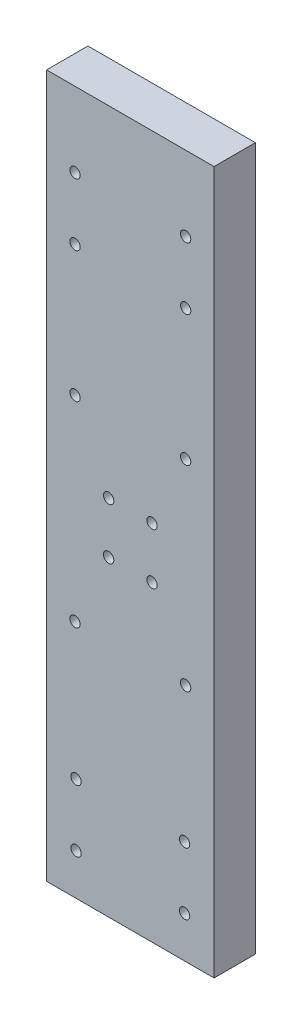
from build123d import *

# Parameters (mm, degrees)
SKETCH1_W           = 16.2
SKETCH1_H           = 67.99
SKETCH1_R           = 0.5
BOSS_EXTRUDE1_DEPTH = 4


with BuildPart() as part:
    # Sketch1 → Boss-Extrude1 (new body)
    with BuildSketch(Plane.XY):
        with Locations((8.1, 33.995)):
            Rectangle(SKETCH1_W, SKETCH1_H)
        with Locations((6, 30.15)):
            Circle(SKETCH1_R, mode=Mode.SUBTRACT)
        with Locations((10.2, 30.15)):
            Circle(SKETCH1_R, mode=Mode.SUBTRACT)
        with Locations((10.2, 35.11)):
            Circle(SKETCH1_R, mode=Mode.SUBTRACT)
        with Locations((13.45, 60.76)):
            Circle(SKETCH1_R, mode=Mode.SUBTRACT)
        with Locations((13.45, 54.76)):
            Circle(SKETCH1_R, mode=Mode.SUBTRACT)
        with Locations((2.75, 60.76)):
            Circle(SKETCH1_R, mode=Mode.SUBTRACT)
        with Locations((6, 35.11)):
            Circle(SKETCH1_R, mode=Mode.SUBTRACT)
        with Locations((2.75, 42.11)):
            Circle(SKETCH1_R, mode=Mode.SUBTRACT)
        with Locations((2.85, 10)):
            Circle(SKETCH1_R, mode=Mode.SUBTRACT)
        with Locations((13.35, 10)):
            Circle(SKETCH1_R, mode=Mode.SUBTRACT)
        with Locations((13.35, 4)):
            Circle(SKETCH1_R, mode=Mode.SUBTRACT)
        with Locations((2.85, 4)):
            Circle(SKETCH1_R, mode=Mode.SUBTRACT)
        with Locations((13.45, 42.11)):
            Circle(SKETCH1_R, mode=Mode.SUBTRACT)
        with Locations((2.75, 54.76)):
            Circle(SKETCH1_R, mode=Mode.SUBTRACT)
        with Locations((13.45, 23.15)):
            Circle(SKETCH1_R, mode=Mode.SUBTRACT)
        with Locations((2.75, 23.15)):
            Circle(SKETCH1_R, mode=Mode.SUBTRACT)
    extrude(amount=BOSS_EXTRUDE1_DEPTH)


solid = part.part
